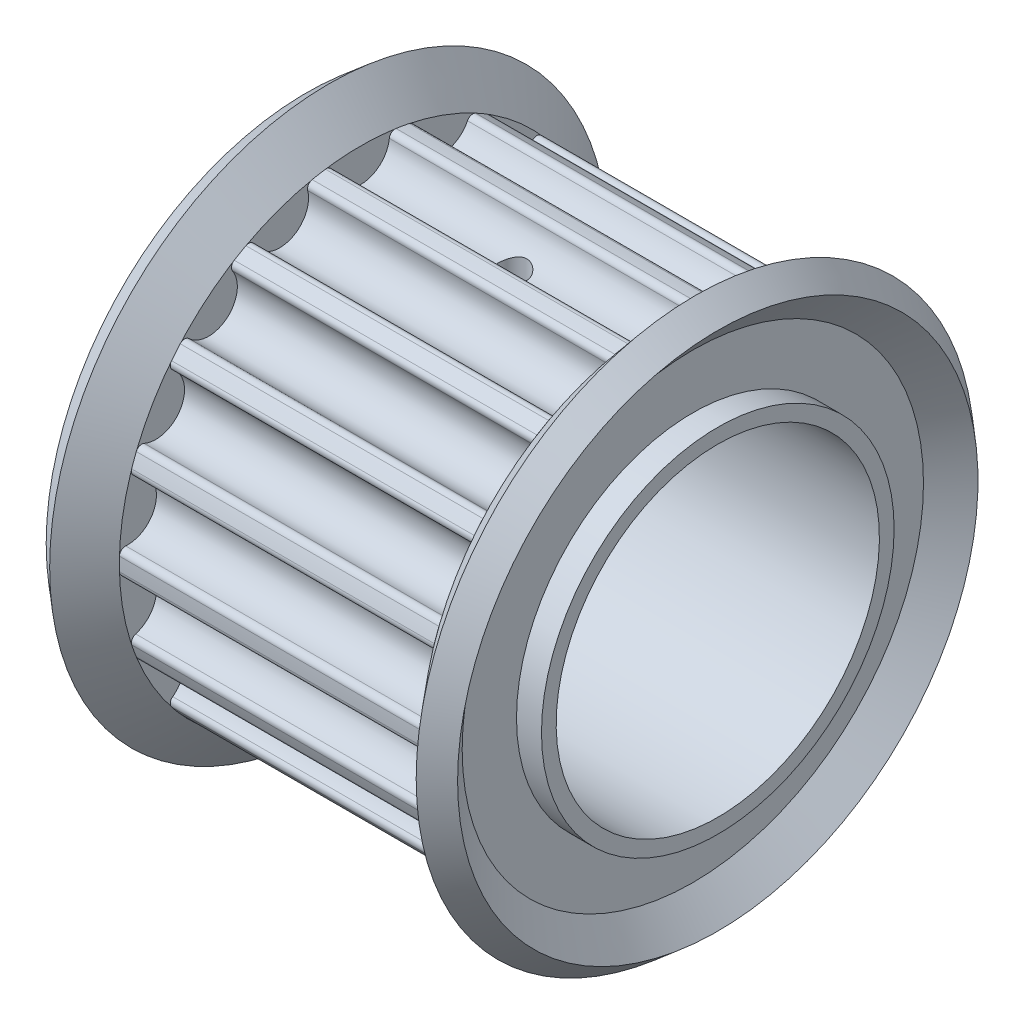
from build123d import *

# Parameters (mm, degrees)
CUT_EXTRUDE1_DEPTH = 8
CIRPATTERN1_COUNT  = 18
SKETCH4_W          = 14
SKETCH4_H          = 5.5
SKETCH5_R          = 0.5
CUT_EXTRUDE2_DEPTH = 10.5


with BuildPart() as part:
    # Sketch1 → Revolve1 (revolve)
    with BuildSketch(Plane.XY):
        Polygon((-7, 4), (7, 4), (7, 6), (5.15, 6), (5.15, 8.215), (-5.15, 8.215), (-5.15, 6), (-7, 6), align=None)
    revolve(axis=Axis((-16.041522885, 0, 0), (1, 0, 0)))

    # Sketch2 → Cut-Extrude1 (cut, symmetric)
    with BuildSketch(Plane(origin=(0, 0, 0), x_dir=(0, 0, -1), z_dir=(1, 0, 0))):
        with BuildLine():
            ThreePointArc((1.2, 8.126882859), (0, 8.215), (-1.2, 8.126882859))
            ThreePointArc((-1.2, 8.126882859), (-1.048214336, 8.087067355), (-0.971883761, 7.949962265))
            ThreePointArc((-0.971883761, 7.949962265), (0, 7.075), (0.971883761, 7.949962265))
            ThreePointArc((0.971883761, 7.949962265), (1.048214336, 8.087067355), (1.2, 8.126882859))
        make_face()
    cut_extrude1 = extrude(amount=CUT_EXTRUDE1_DEPTH, both=True, mode=Mode.SUBTRACT)

    # CirPattern1: Cut-Extrude1 ×18 about axis
    cirpattern1_axis = Axis((0, 0, 0), (1, 0, 0))
    for i in range(1, CIRPATTERN1_COUNT):
        add(cut_extrude1.rotate(cirpattern1_axis, i * 360 / CIRPATTERN1_COUNT), mode=Mode.SUBTRACT)

    # Sketch4 → Cut-Revolve1 (revolve, cut)
    with BuildSketch(Plane.XY):
        with Locations((0, 2.75)):
            Rectangle(SKETCH4_W, SKETCH4_H)
    revolve(axis=Axis((0, 0, 0), (-1, 0, 0)), mode=Mode.SUBTRACT)

    # Sketch5 → Cut-Extrude2 (cut, through all)
    with BuildSketch(Plane(origin=(0, 0, 0), x_dir=(1, 0, 0), z_dir=(0, 1, 0))):
        Circle(SKETCH5_R)
    extrude(amount=CUT_EXTRUDE2_DEPTH, mode=Mode.SUBTRACT)


with BuildPart() as body_2:
    # Sketch3 → Revolve2 (revolve)
    with BuildSketch(Plane.XY):
        Polygon((5.15, 6), (6.15, 6), (6.15, 7.848944657), (7, 8.854397763), (6.236326148, 9.5), (5.15, 8.215), align=None)
        Polygon((-5.15, 6), (-5.15, 8.215), (-6.236326148, 9.5), (-7, 8.854397763), (-6.15, 7.848944657), (-6.15, 6), align=None)
    revolve(axis=Axis((0, 0, 0), (1, 0, 0)))


solid = Compound([part.part, body_2.part])
